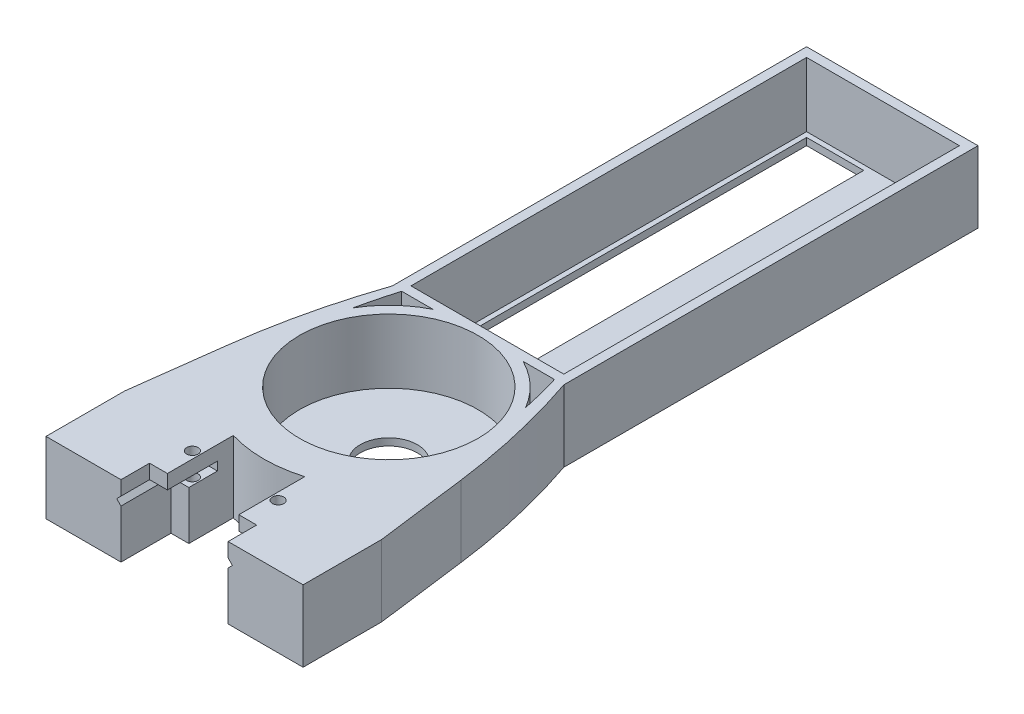
from build123d import *

# Parameters (mm, degrees)
RESSALTO_EXTRUS_O1_DEPTH   = 11
RESSALTO_EXTRUS_O1_2_DEPTH = 11
RESSALTO_EXTRUS_O2_START   = -5
ESBO_O3_R                  = 12.5
ESBO_O3_W                  = 8
ESBO_O3_H                  = 54
RESSALTO_EXTRUS_O2_DEPTH   = 10
ESBO_O4_W                  = 21.4
ESBO_O4_H                  = 55.4
CORTE_EXTRUS_O1_DEPTH      = 9
CORTE_EXTRUS_O2_REACH      = 12
ESBO_O5_W                  = 2.5
ESBO_O5_H                  = 7
ESBO_O6_R                  = 0.8
ESBO_O6_W                  = 15
ESBO_O6_H                  = 4
CORTE_EXTRUS_O3_DEPTH      = 11
CORTE_EXTRUS_O4_DEPTH      = 1
CORTE_EXTRUS_O4_DEPTH_BACK = 11
ESBO_O10_R                 = 12.5
ESBO_O10_R_2               = 4
RESSALTO_EXTRUS_O3_DEPTH   = 1


with BuildPart() as part:
    # Esboço1 → Ressalto-extrusão1 (new body)
    with BuildSketch(Plane.XY):
        Polygon((-5, 1.8), (-5, -5), (-14.1, -5), (-14.1, 5), (-5, 5), (-5, 3), (-7.5, 3), (-8.1, 2.4), (-7.5, 1.8), align=None)
    extrude(amount=RESSALTO_EXTRUS_O1_DEPTH)



with BuildPart() as body_2:
    # Esboço1 → Ressalto-extrus_o1 2 (new body)
    with BuildSketch(Plane.XY):
        Polygon((7.5, 1.8), (5, 1.8), (5, -5), (14.1, -5), (14.1, 5), (5, 5), (5, 3), (7.5, 3), (8.1, 2.4), align=None)
    extrude(amount=RESSALTO_EXTRUS_O1_2_DEPTH)


with BuildPart() as part_1:
    add(part.part)

    add(body_2.part)  # Ressalto-extrusão2 merges body 2
    # Esboço3 → Ressalto-extrusão2 (add, through all)
    with BuildSketch(Plane(origin=(0, 0, 0), x_dir=(1, 0, 0), z_dir=(0, 1, 0)).offset(RESSALTO_EXTRUS_O2_START)):
        with BuildLine():
            Line((-14.1, -11), (-14.1, 0))
            Line((-14.1, 0), (-5, 0))
            Line((-5, 0), (-5, 2.229490169))
            ThreePointArc((-5, 2.229490169), (0, 1.5), (5, 2.229490169))
            Line((5, 2.229490169), (5, 0))
            Line((5, 0), (14.1, 0))
            Line((14.1, 0), (14.1, -11))
            Line((14.1, -11), (18, -11))
            Line((18, -11), (18, 0))
            Line((18, 0), (16.353425267, 12.769792778))
            ThreePointArc((16.353425267, 12.769792778), (14.646005419, 22.243973189), (12, 31.5))
            Line((12, 31.5), (12, 89.5))
            Line((12, 89.5), (-12, 89.5))
            Line((-12, 89.5), (-12, 31.5))
            ThreePointArc((-12, 31.5), (-14.646005419, 22.243973189), (-16.353425267, 12.769792778))
            Line((-16.353425267, 12.769792778), (-18, 0))
            Line((-18, 0), (-18, -11))
            Line((-18, -11), (-14.1, -11))
        make_face()
        with Locations((0, 19)):
            Circle(ESBO_O3_R, mode=Mode.SUBTRACT)
        with Locations((-6, 60.5)):
            Rectangle(ESBO_O3_W, ESBO_O3_H, mode=Mode.SUBTRACT)
        with Locations((6, 60.5)):
            Rectangle(ESBO_O3_W, ESBO_O3_H, mode=Mode.SUBTRACT)
    extrude(amount=RESSALTO_EXTRUS_O2_DEPTH)

    # Esboço4 → Corte-extrusão1 (cut)
    with BuildSketch(Plane(origin=(0, 5, 0), x_dir=(1, 0, 0), z_dir=(0, 1, 0))):
        with Locations((0, 60.5)):
            Rectangle(ESBO_O4_W, ESBO_O4_H)
    extrude(amount=-CORTE_EXTRUS_O1_DEPTH, mode=Mode.SUBTRACT)

    # Esboço5 → Corte-extrusão2 (cut, up to next)
    with BuildSketch(Plane.XZ.offset(5), mode=Mode.PRIVATE) as corte_extrus_o2_sk1:
        with Locations((-6.25, 7.5)):
            Rectangle(ESBO_O5_W, ESBO_O5_H)
    corte_extrus_o2_tool1 = extrude(corte_extrus_o2_sk1.sketch, amount=-CORTE_EXTRUS_O2_REACH, mode=Mode.PRIVATE) & part_1.part
    add(corte_extrus_o2_tool1.solids().sort_by_distance((-6.25, -5, 7.5))[0], mode=Mode.SUBTRACT)
    # Esboço5 → Corte-extrusão2 (cut, up to next)
    with BuildSketch(Plane.XZ.offset(5), mode=Mode.PRIVATE) as corte_extrus_o2_sk2:
        with Locations((6.25, 7.5)):
            Rectangle(ESBO_O5_W, ESBO_O5_H)
    corte_extrus_o2_tool2 = extrude(corte_extrus_o2_sk2.sketch, amount=-CORTE_EXTRUS_O2_REACH, mode=Mode.PRIVATE) & part_1.part
    add(corte_extrus_o2_tool2.solids().sort_by_distance((6.25, -5, 7.5))[0], mode=Mode.SUBTRACT)

    # Esboço6 → Corte-extrusão3 (cut, through all)
    with BuildSketch(Plane(origin=(0, 5, 0), x_dir=(1, 0, 0), z_dir=(0, 1, 0))):
        with Locations((-6, -2.5)):
            Circle(ESBO_O6_R)
        with Locations((6, -2.5)):
            Circle(ESBO_O6_R)
        with Locations((0, -9)):
            Rectangle(ESBO_O6_W, ESBO_O6_H)
    extrude(amount=-CORTE_EXTRUS_O3_DEPTH, mode=Mode.SUBTRACT)

    # Esboço9 → Corte-extrusão4 (cut, two sides)
    with BuildSketch(Plane(origin=(0, 5, 0), x_dir=(1, 0, 0), z_dir=(0, 1, 0))) as corte_extrus_o4_sk:
        with BuildLine():
            Line((6.304760106, 31.5), (10.7, 31.5))
            ThreePointArc((10.7, 31.5), (11.444665091, 28.788992569), (12.093349717, 26.053431266))
            ThreePointArc((12.093349717, 26.053431266), (9.593690062, 29.196132158), (6.304760106, 31.5))
        make_face()
        with BuildLine():
            Line((-6.304760106, 31.5), (-10.7, 31.5))
            ThreePointArc((-10.7, 31.5), (-11.444665091, 28.788992569), (-12.093349717, 26.053431266))
            ThreePointArc((-12.093349717, 26.053431266), (-9.593690062, 29.196132158), (-6.304760106, 31.5))
        make_face()
    extrude(amount=CORTE_EXTRUS_O4_DEPTH, mode=Mode.SUBTRACT)
    extrude(corte_extrus_o4_sk.sketch, amount=-CORTE_EXTRUS_O4_DEPTH_BACK, mode=Mode.SUBTRACT)

    # Esboço10 → Ressalto-extrusão3 (add)
    with BuildSketch(Plane.XZ.offset(5)):
        with Locations((0, -19)):
            Circle(ESBO_O10_R)
        with Locations((0, -19)):
            Circle(ESBO_O10_R_2, mode=Mode.SUBTRACT)
    extrude(amount=-RESSALTO_EXTRUS_O3_DEPTH)


solid = part_1.part
